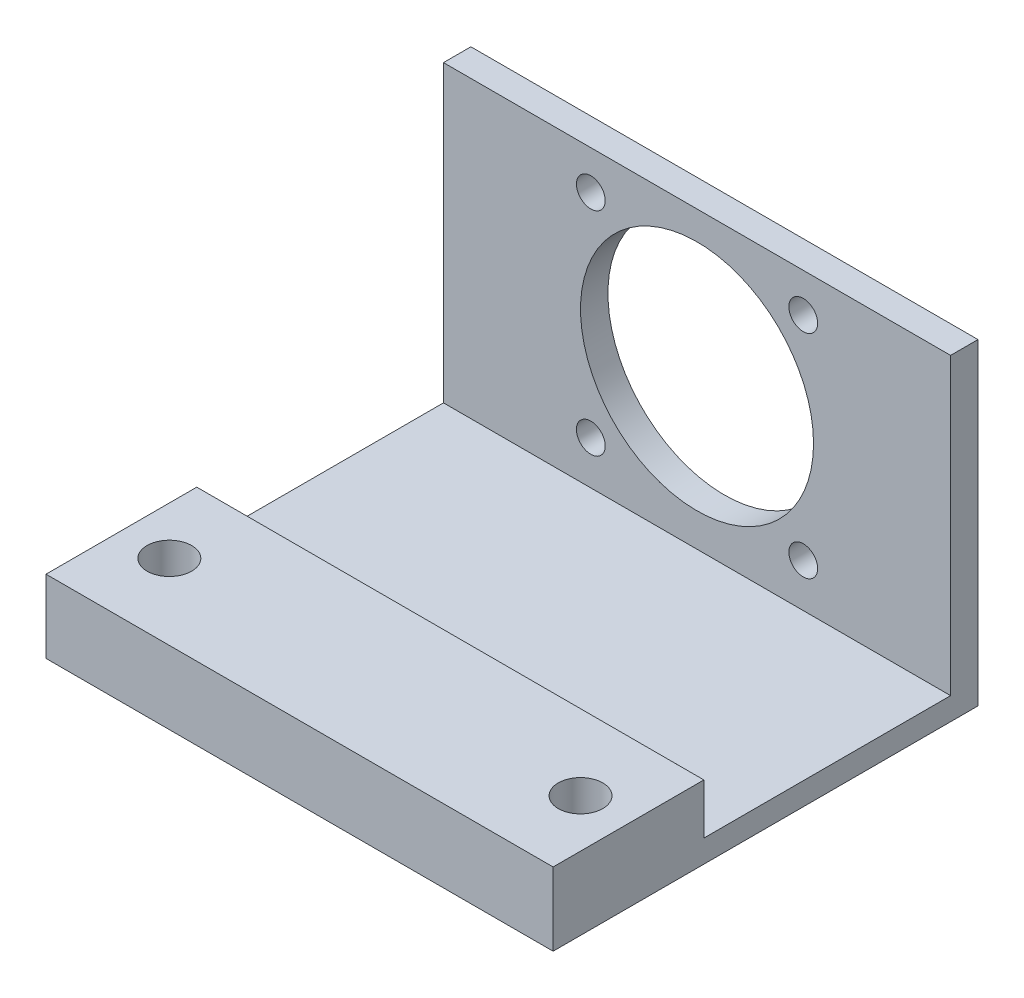
from build123d import *

# Parameters (mm, degrees)
CROQUIS1_W              = 74
CROQUIS1_H              = 46.3
CROQUIS1_R              = 17
CROQUIS1_R_2            = 2.1
SALIENTE_EXTRUIR1_DEPTH = 4
SALIENTE_EXTRUIR3_DEPTH = 74
CORTAR_EXTRUIR2_REACH   = 12.65
CROQUIS6_R              = 3.25


with BuildPart() as part:
    # Croquis1 → Saliente-Extruir1 (new body)
    with BuildSketch(Plane.XY):
        with Locations((0, -2)):
            Rectangle(CROQUIS1_W, CROQUIS1_H)
        Circle(CROQUIS1_R, mode=Mode.SUBTRACT)
        with Locations((-15.5, -15.5)):
            Circle(CROQUIS1_R_2, mode=Mode.SUBTRACT)
        with Locations((-15.5, 15.5)):
            Circle(CROQUIS1_R_2, mode=Mode.SUBTRACT)
        with Locations((15.5, -15.5)):
            Circle(CROQUIS1_R_2, mode=Mode.SUBTRACT)
        with Locations((15.5, 15.5)):
            Circle(CROQUIS1_R_2, mode=Mode.SUBTRACT)
    extrude(amount=SALIENTE_EXTRUIR1_DEPTH)

    # Croquis5 → Saliente-Extruir3 (add)
    with BuildSketch(Plane.ZY.offset(37)):
        Polygon((4, -25.15), (62, -25.15), (62, -14.5), (40, -14.5), (40, -21.85), (4, -21.85), align=None)
    extrude(amount=-SALIENTE_EXTRUIR3_DEPTH)

    # Croquis6 → Cortar-Extruir2 (cut, up to next)
    with BuildSketch(Plane(origin=(0, -14.5, 0), x_dir=(1, 0, 0), z_dir=(0, 1, 0)), mode=Mode.PRIVATE) as cortar_extruir2_sk1:
        with Locations((-30, -51)):
            Circle(CROQUIS6_R)
    cortar_extruir2_tool1 = extrude(cortar_extruir2_sk1.sketch, amount=-CORTAR_EXTRUIR2_REACH, mode=Mode.PRIVATE) & part.part
    add(cortar_extruir2_tool1.solids().sort_by_distance((-30, -14.5, 51))[0], mode=Mode.SUBTRACT)
    # Croquis6 → Cortar-Extruir2 (cut, up to next)
    with BuildSketch(Plane(origin=(0, -14.5, 0), x_dir=(1, 0, 0), z_dir=(0, 1, 0)), mode=Mode.PRIVATE) as cortar_extruir2_sk2:
        with Locations((30, -51)):
            Circle(CROQUIS6_R)
    cortar_extruir2_tool2 = extrude(cortar_extruir2_sk2.sketch, amount=-CORTAR_EXTRUIR2_REACH, mode=Mode.PRIVATE) & part.part
    add(cortar_extruir2_tool2.solids().sort_by_distance((30, -14.5, 51))[0], mode=Mode.SUBTRACT)


solid = part.part
